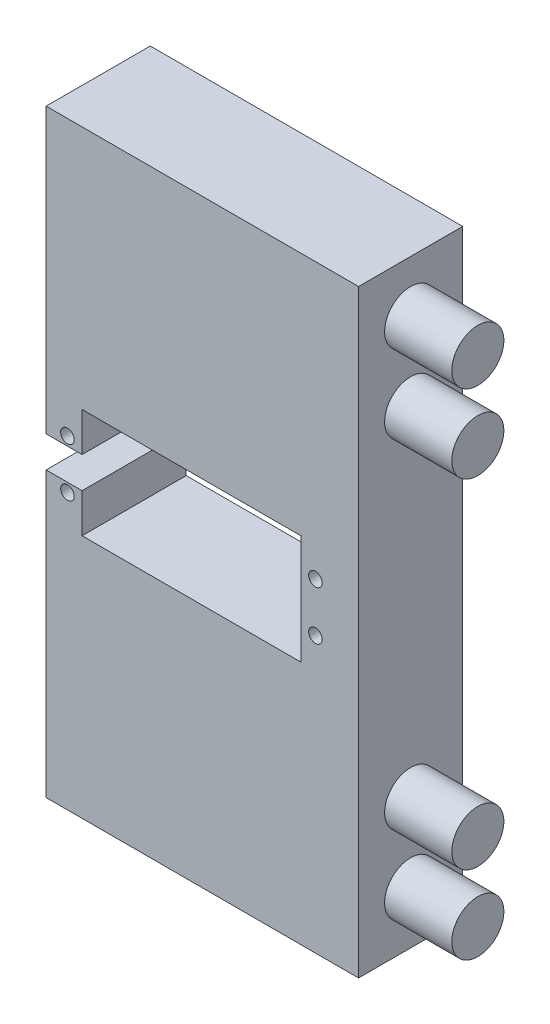
from build123d import *

# Parameters (mm, degrees)
SKETCH_5_W          = 60
SKETCH_5_H          = 115
EXTRUDE_2_DEPTH     = 20
SKETCH_1_R          = 1.3
CUT_EXTRUDE_4_DEPTH = 20
SKETCH_6_R          = 5
EXTRUDE_3_DEPTH     = 13
SKETCH_22_R         = 9.5
CUT_EXTRUDE_5_DEPTH = 15
SKETCH_22_10_R      = 9.5
CUT_EXTRUDE_6_DEPTH = 15


with BuildPart() as part:
    # Sketch 5 → Extrude 2 (new body)
    with BuildSketch(Plane.XY):
        with Locations((85.095319229, -3)):
            Rectangle(SKETCH_5_W, SKETCH_5_H)
    extrude(amount=EXTRUDE_2_DEPTH)

    # Sketch 1 → Cut-Extrude 4 (cut)
    with BuildSketch(Plane.XY):
        with Locations((59.19, 1.7)):
            Circle(SKETCH_1_R)
        with Locations((106.81, 1.7)):
            Circle(SKETCH_1_R)
        with Locations((106.81, -7.7)):
            Circle(SKETCH_1_R)
        with Locations((59.19, -7.7)):
            Circle(SKETCH_1_R)
        Polygon((55, -3), (55, 0), (62, 0), (62, 7.5), (104, 7.5), (104, -13.5), (62, -13.5), (62, -6), (55, -6), align=None)
    extrude(amount=CUT_EXTRUDE_4_DEPTH, mode=Mode.SUBTRACT)

    # Sketch 6 → Extrude 3 (add)
    with BuildSketch(Plane(origin=(115, 0, 0), x_dir=(0, 0, -1), z_dir=(1, 0, 0))):
        with Locations((-10, 44.5)):
            Circle(SKETCH_6_R)
        with Locations((-10, 29.5)):
            Circle(SKETCH_6_R)
        with Locations((-10, -35.5)):
            Circle(SKETCH_6_R)
        with Locations((-10, -50.5)):
            Circle(SKETCH_6_R)
    extrude(amount=EXTRUDE_3_DEPTH)

    # Sketch 22 → Cut-Extrude 5 (cut)
    with BuildSketch(Plane.XY):
        with Locations((85, 37.5)):
            Circle(SKETCH_22_R)
    extrude(amount=CUT_EXTRUDE_5_DEPTH, mode=Mode.SUBTRACT)

    # Sketch 22_10 → Cut-Extrude 6 (cut)
    with BuildSketch(Plane.XY):
        with Locations((85, -43.5)):
            Circle(SKETCH_22_10_R)
    extrude(amount=CUT_EXTRUDE_6_DEPTH, mode=Mode.SUBTRACT)


solid = part.part
